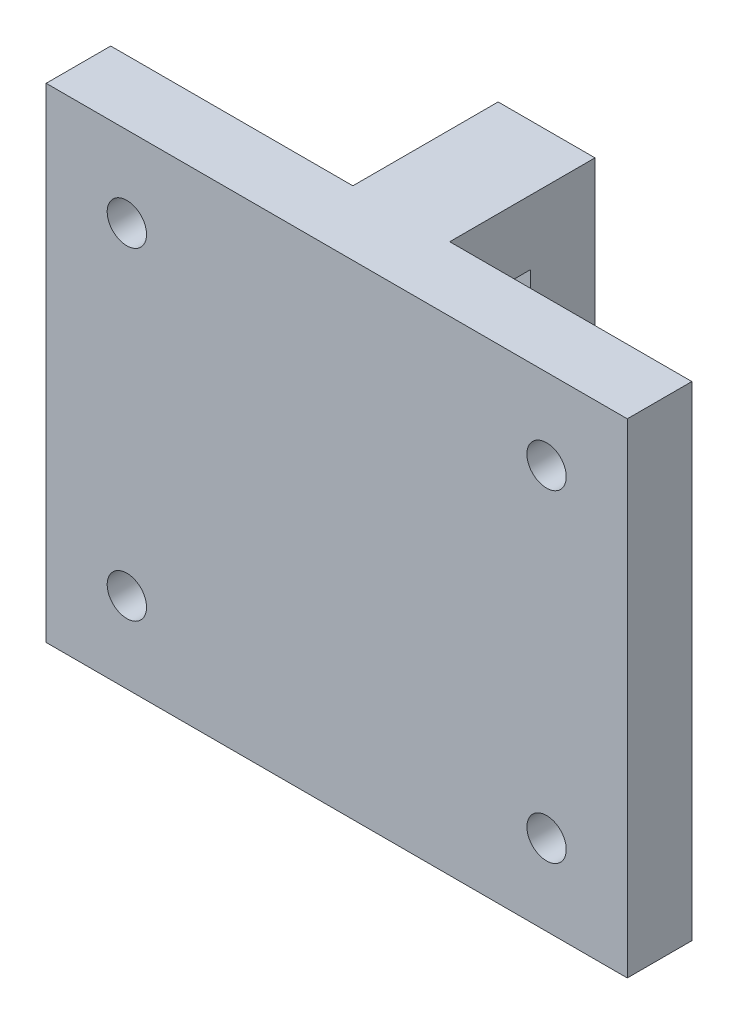
from build123d import *

# Parameters (mm, degrees)
BOSS_EXTRUDE1_DEPTH                               = 3
SKETCH2_W                                         = 36
SKETCH2_H                                         = 30
BOSS_EXTRUDE2_DEPTH                               = 4
CSK_FOR_2_FLAT_HEAD_MACHINE_SCREW_100_D           = 2.4384
CSK_FOR_2_FLAT_HEAD_MACHINE_SCREW_100_CSINK_D     = 4.3688
CSK_FOR_2_FLAT_HEAD_MACHINE_SCREW_100_CSINK_ANGLE = 100


with BuildPart() as part:
    # Sketch1 → Boss-Extrude1 (new body, symmetric)
    with BuildSketch(Plane(origin=(0, 0, 0), x_dir=(0, 0, -1), z_dir=(1, 0, 0))):
        Polygon((4, 26), (9, 26), (9, 16), (13, 16), (13, 30), (0, 30), (0, 0), (4, 0), align=None)
    extrude(amount=BOSS_EXTRUDE1_DEPTH, both=True)

    # Sketch2 → Boss-Extrude2 (add)
    with BuildSketch(Plane.XY):
        with Locations((0, 15)):
            Rectangle(SKETCH2_W, SKETCH2_H)
    extrude(amount=-BOSS_EXTRUDE2_DEPTH)

    # CSK for #2 Flat Head Machine Screw (100)1 (through all)
    with Locations(Plane(origin=(0, 0, -4), x_dir=(-1, 0, 0), z_dir=(0, 0, -1))):
        with Locations((-13, 25), (-13, 5), (13, 5), (13, 25)):
            CounterSinkHole(CSK_FOR_2_FLAT_HEAD_MACHINE_SCREW_100_D / 2, CSK_FOR_2_FLAT_HEAD_MACHINE_SCREW_100_CSINK_D / 2, counter_sink_angle=CSK_FOR_2_FLAT_HEAD_MACHINE_SCREW_100_CSINK_ANGLE)


solid = part.part
